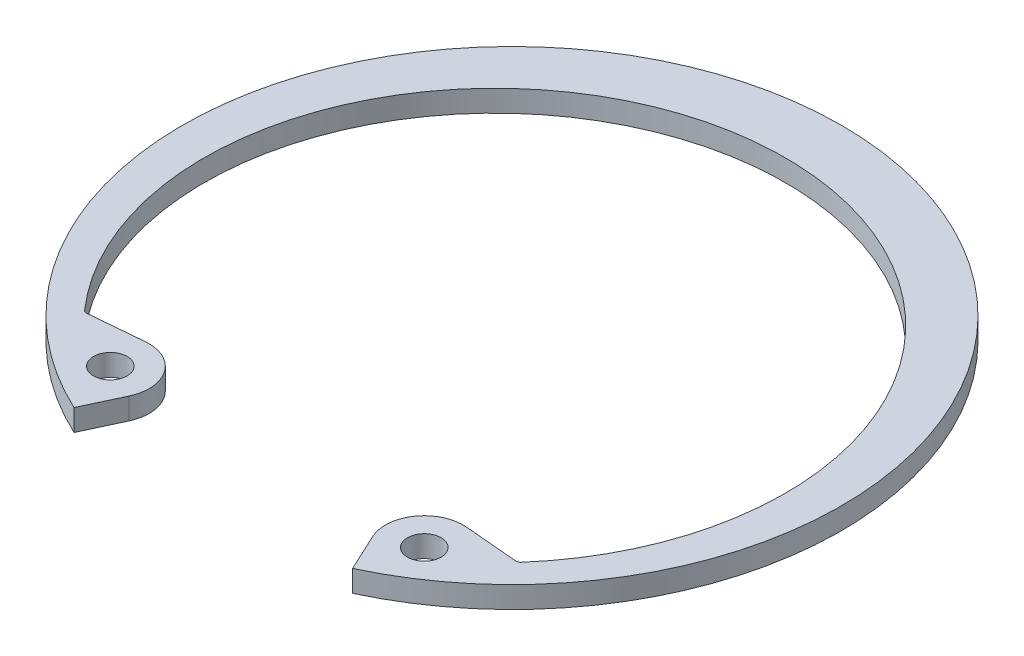
from build123d import *

# Parameters (mm, degrees)
SKETCH2_R      = 0.9906
EXTRUDE1_DEPTH = 1.27
FILLET1_R      = 0.254


with BuildPart() as part:
    # Sketch2 → Extrude1 (new body)
    with BuildSketch(Plane(origin=(0, 0, 0), x_dir=(1, 0, 0), z_dir=(0, 1, 0))):
        with BuildLine():
            Line((8.190426436, -17.564426174), (7.159431239, -15.353449839))
            ThreePointArc((7.159431239, -15.353449839), (7.358669267, -13.07614876), (9.430488868, -12.110043413))
            Line((9.430488868, -12.110043413), (12.742568128, -12.399812801))
            ThreePointArc((12.742568128, -12.399812801), (0, 16.0782), (-12.742568128, -12.399812801))
            Line((-12.742568128, -12.399812801), (-9.430488868, -12.110043413))
            ThreePointArc((-9.430488868, -12.110043413), (-7.358669267, -13.07614876), (-7.159431239, -15.353449839))
            Line((-7.159431239, -15.353449839), (-8.190426436, -17.564426174))
            ThreePointArc((-8.190426436, -17.564426174), (0, 19.3802), (8.190426436, -17.564426174))
        make_face()
        with Locations((9.23125084, -14.387344493)):
            Circle(SKETCH2_R, mode=Mode.SUBTRACT)
        with Locations((-9.23125084, -14.387344493)):
            Circle(SKETCH2_R, mode=Mode.SUBTRACT)
    extrude(amount=-EXTRUDE1_DEPTH)

    # Fillet1
    fillet1_edges = [part.edges().sort_by_distance(p)[0] for p in [
        (12.742568128, -0.635, 12.399812801),
        (-12.742568128, -0.635, 12.399812801),
    ]]
    fillet(fillet1_edges, radius=FILLET1_R)


solid = part.part
